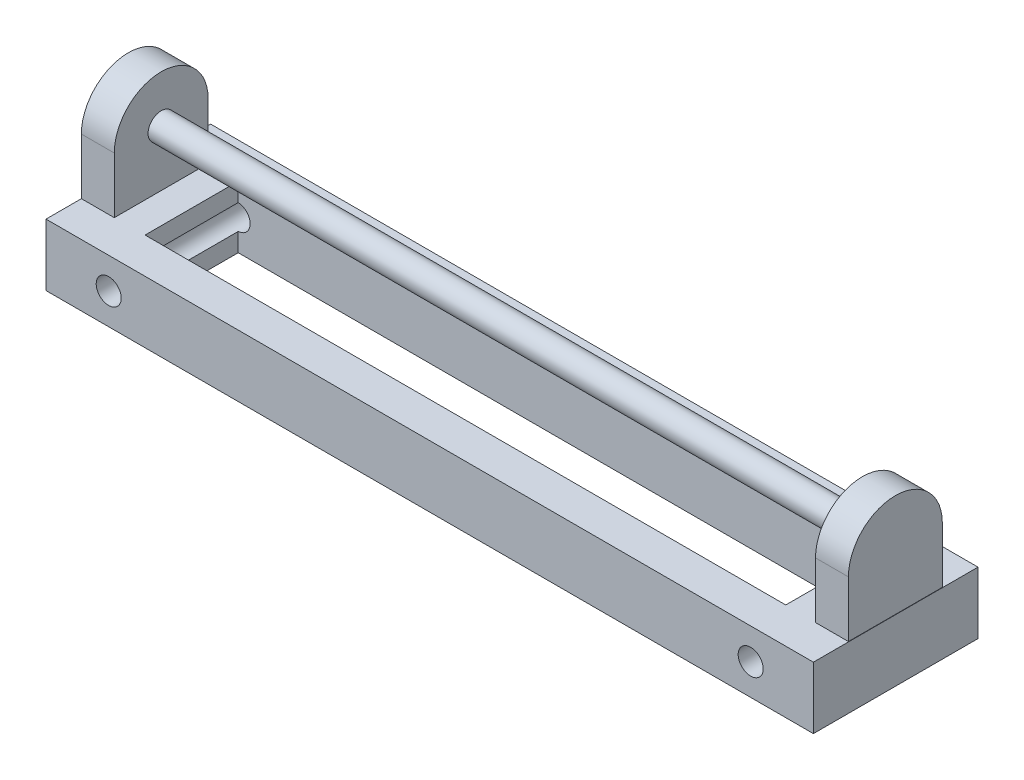
from build123d import *

# Parameters (mm, degrees)
SKETCH1_W           = 233.09940225
SKETCH1_H           = 18.807132604
SKETCH1_R           = 3.7970867
BOSS_EXTRUDE1_DEPTH = 50
SKETCH3_R           = 4.00110176
BOSS_EXTRUDE2_DEPTH = 10
BOSS_EXTRUDE5_START = -223
SKETCH3_2_R         = 4.00110176
BOSS_EXTRUDE5_DEPTH = 10
BOSS_EXTRUDE6_START = -233
SKETCH4_R           = 4.00110176
BOSS_EXTRUDE6_DEPTH = 233
CUT_EXTRUDE1_REACH  = 217.955
SKETCH5_W           = 194.621538706
SKETCH5_H           = 28.304823728


with BuildPart() as part:
    # Sketch1 → Boss-Extrude1 (new body)
    with BuildSketch(Plane.XY):
        with Locations((87.483442541, -10.016557459)):
            Rectangle(SKETCH1_W, SKETCH1_H)
        with Locations((-10.016557459, -10.016557459)):
            Circle(SKETCH1_R, mode=Mode.SUBTRACT)
        with Locations((184.983442541, -10.016557459)):
            Circle(SKETCH1_R, mode=Mode.SUBTRACT)
    extrude(amount=BOSS_EXTRUDE1_DEPTH)

    # Sketch3 → Boss-Extrude2 (add)
    with BuildSketch(Plane.ZY.offset(29.066258584)):
        with BuildLine():
            Line((10.743495107, -0.612991157), (10.743495107, 16.393198277))
            ThreePointArc((10.743495107, 16.393198277), (25, 30.64970317), (39.256504893, 16.393198277))
            Line((39.256504893, 16.393198277), (39.256504893, -0.612991157))
            Line((39.256504893, -0.612991157), (10.743495107, -0.612991157))
        make_face()
        with Locations((25, 16.393198277)):
            Circle(SKETCH3_R, mode=Mode.SUBTRACT)
    extrude(amount=-BOSS_EXTRUDE2_DEPTH)

    # Sketch3_2 → Boss-Extrude5 (add)
    with BuildSketch(Plane.ZY.offset(29.066258584).offset(BOSS_EXTRUDE5_START)):
        with BuildLine():
            Line((10.743495107, -0.612991157), (10.743495107, 16.393198277))
            ThreePointArc((10.743495107, 16.393198277), (25, 30.64970317), (39.256504893, 16.393198277))
            Line((39.256504893, 16.393198277), (39.256504893, -0.612991157))
            Line((39.256504893, -0.612991157), (10.743495107, -0.612991157))
        make_face()
        with Locations((25, 16.393198277)):
            Circle(SKETCH3_2_R, mode=Mode.SUBTRACT)
    extrude(amount=-BOSS_EXTRUDE5_DEPTH)

    # Sketch4 → Boss-Extrude6 (add)
    with BuildSketch(Plane(origin=(203.933741416, 0, 0), x_dir=(0, 0, -1), z_dir=(1, 0, 0)).offset(BOSS_EXTRUDE6_START)):
        with Locations((-25, 16.393198277)):
            Circle(SKETCH4_R)
    extrude(amount=BOSS_EXTRUDE6_DEPTH)

    # Sketch5 → Cut-Extrude1 (cut, up to next)
    with BuildSketch(Plane.XZ.offset(19.420123761), mode=Mode.PRIVATE) as cut_extrude1_sk1:
        with Locations((87.483442541, 25)):
            Rectangle(SKETCH5_W, SKETCH5_H)
    cut_extrude1_tool1 = extrude(cut_extrude1_sk1.sketch, amount=-CUT_EXTRUDE1_REACH, mode=Mode.PRIVATE) & part.part
    add(cut_extrude1_tool1.solids().sort_by_distance((87.483443, -19.420124, 25))[0], mode=Mode.SUBTRACT)


solid = part.part
